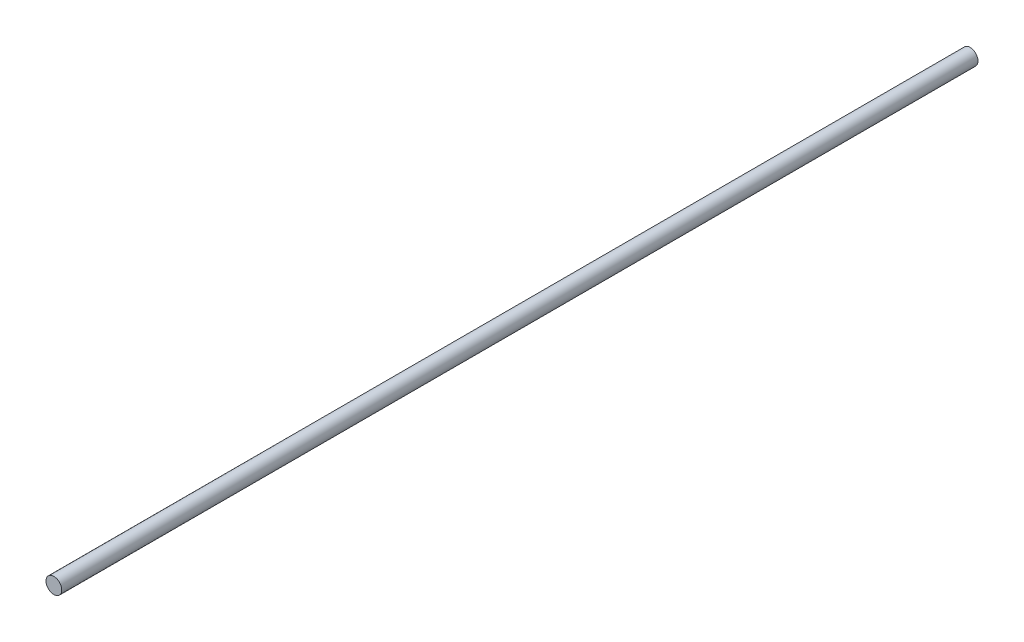
from build123d import *

# Parameters (mm, degrees)
SKETCH_1_R      = 4
EXTRUDE_1_DEPTH = 465


with BuildPart() as part:
    # 草图1 → 凸台-拉伸1 (new body)
    with BuildSketch(Plane.XY):
        Circle(SKETCH_1_R)
    extrude(amount=EXTRUDE_1_DEPTH)


solid = part.part
